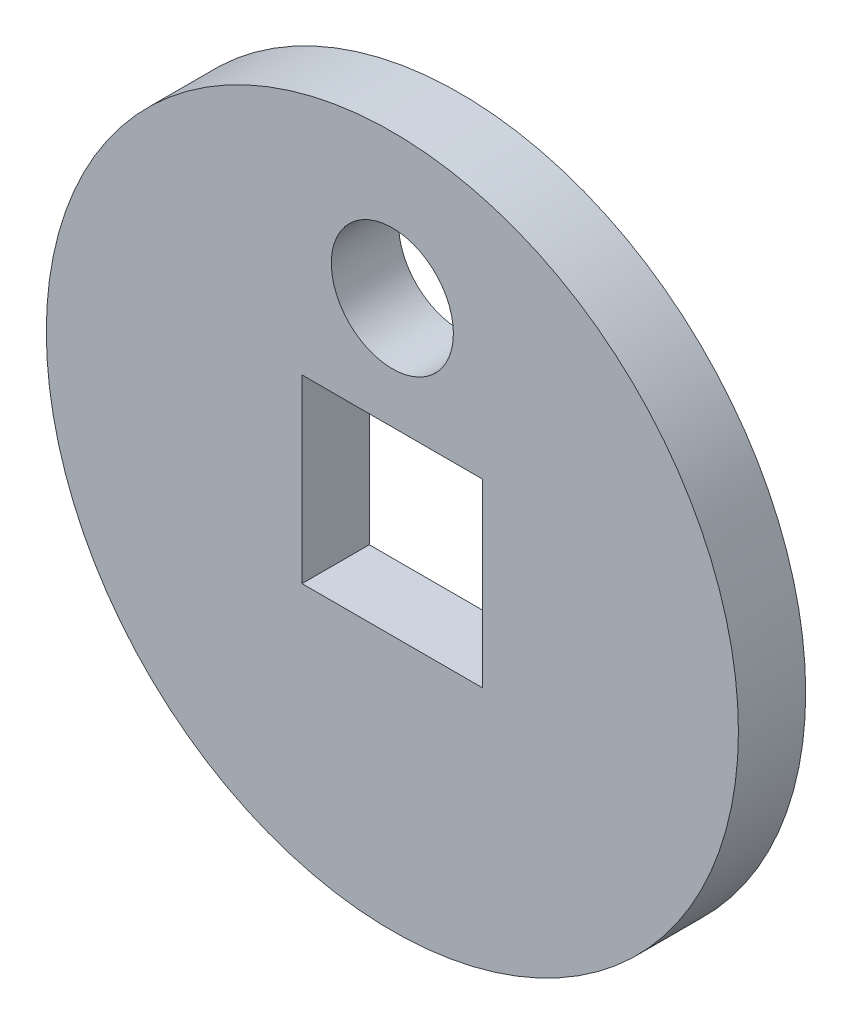
from build123d import *

# Parameters (mm, degrees)
SKETCH1_R           = 9
BOSS_EXTRUDE1_DEPTH = 1.75
SKETCH2_R           = 1.5875
SKETCH2_W           = 4.7
SKETCH2_H           = 4.7
CUT_EXTRUDE1_DEPTH  = 2.75


with BuildPart() as part:
    # Sketch1 → Boss-Extrude1 (new body)
    with BuildSketch(Plane.XY):
        Circle(SKETCH1_R)
    extrude(amount=BOSS_EXTRUDE1_DEPTH)

    # Sketch2 → Cut-Extrude1 (cut, through all)
    with BuildSketch(Plane.XY.offset(1.75)):
        with Locations((0, 5.25)):
            Circle(SKETCH2_R)
        Rectangle(SKETCH2_W, SKETCH2_H)
    extrude(amount=-CUT_EXTRUDE1_DEPTH, mode=Mode.SUBTRACT)


solid = part.part
